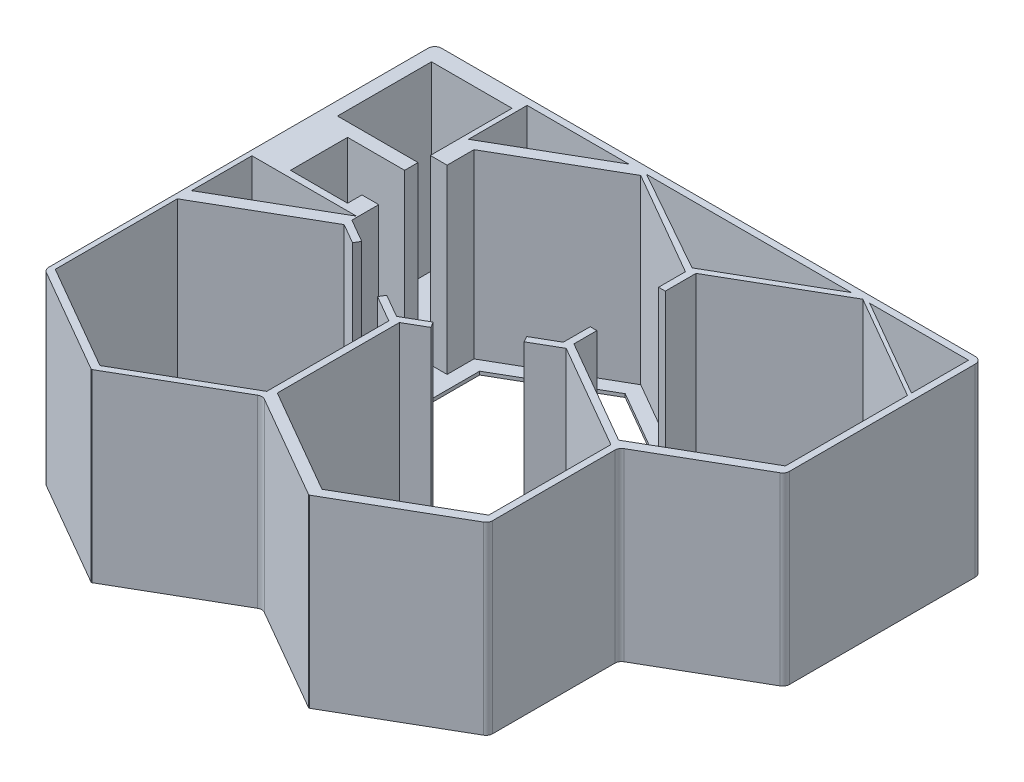
from build123d import *

# Parameters (mm, degrees)
SKETCH1_W               = 207.01
SKETCH1_H               = 171.45
BOSS_EXTRUDE1_DEPTH     = 69.85
CUT_EXTRUDE1_DEPTH      = 68.58
CUT_EXTRUDE2_DEPTH      = 1
CUT_EXTRUDE2_DEPTH_BACK = 70.85
FILLET3_R               = 2.54


with BuildPart() as part:
    # Sketch1 → Boss-Extrude1 (new body)
    with BuildSketch(Plane(origin=(0, 0, 0), x_dir=(1, 0, 0), z_dir=(0, 1, 0))):
        with Locations((103.505, -85.725)):
            Rectangle(SKETCH1_W, SKETCH1_H)
    extrude(amount=BOSS_EXTRUDE1_DEPTH)

    # Sketch3 → Cut-Extrude1 (cut)
    with BuildSketch(Plane(origin=(0, 69.85, 0), x_dir=(1, 0, 0), z_dir=(0, 1, 0))):
        Polygon((1.905, -93.98), (41.499681461, -71.12), (1.905, -71.12), align=None)
        Polygon((41.91, -76.230101608), (1.905, -99.326999127), (1.905, -145.520794165), (41.91, -168.617691684), (81.915, -145.520794165), (81.915, -99.326999127), (71.846181898, -93.513764285), (73.116181898, -91.314059759), (81.915, -96.394059759), (90.713818102, -91.314059759), (91.983818102, -93.513764285), (84.455, -97.860529443), (84.455, -144.054324481), (124.46, -167.151222), (164.465, -144.054324481), (164.465, -97.860529443), (124.46, -74.763631924), (114.391181898, -80.576866766), (113.121181898, -78.377162241), (121.92, -73.297162241), (121.92, -63.137162241), (124.46, -63.137162241), (124.46, -71.830692557), (164.465, -94.927590076), (204.47, -71.830692557), (204.47, -25.636897519), (164.465, -2.54), (124.46, -25.636897519), (124.46, -37.263367203), (121.92, -37.263367203), (121.92, -27.103367203), (81.915, -4.006469684), (41.91, -27.103367203), (41.91, -37.263367203), (35.56, -37.263367203), (35.56, -6.35), (5.08, -6.35), (5.08, -41.91), (35.56, -41.91), (35.56, -46.99), (13.97, -46.99), (13.97, -68.58), (35.56, -68.58), (35.56, -63.137162241), (41.91, -63.137162241), (41.91, -73.297162241), (50.708818102, -78.377162241), (49.438818102, -80.576866766), align=None)
        Polygon((37.465, -24.765), (75.959829198, -2.54), (37.465, -2.54), align=None)
        Polygon((167.075023065, -2.54), (204.47, -24.13), (204.47, -2.54), align=None)
        Polygon((82.645969059, -2.54), (121.92, -24.592453018), (160.115969059, -2.54), align=None)
    extrude(amount=-CUT_EXTRUDE1_DEPTH, mode=Mode.SUBTRACT)

    # Sketch4 → Cut-Extrude2 (cut, two sides)
    with BuildSketch(Plane(origin=(0, 69.85, 0), x_dir=(1, 0, 0), z_dir=(0, 1, 0))) as cut_extrude2_sk:
        Polygon((207.01, -74.315776706), (167.005, -97.412674225), (167.005, -146.601672765), (123.966434747, -171.45), (167.005, -171.45), (207.01, -171.45), align=None)
        Polygon((0, -147.53821025), (41.416434747, -171.45), (0, -171.45), align=None)
        Polygon((41.670434747, -171.45), (123.712434747, -171.45), (82.691434747, -147.766514608), align=None)
        Polygon((81.915, -9.872348419), (46.99, -30.03630657), (46.99, -70.364222873), (81.915, -90.528181024), (116.84, -70.364222873), (116.84, -30.03630657), align=None)
        Polygon((164.465, -8.405878735), (129.54, -28.569836886), (129.54, -68.897753189), (164.465, -89.061711341), (199.39, -68.897753189), (199.39, -28.569836886), align=None)
        Polygon((41.91, -82.095980343), (6.985, -102.259938494), (6.985, -142.587854797), (41.91, -162.751812949), (76.835, -142.587854797), (76.835, -102.259938494), align=None)
        Polygon((124.46, -80.629510659), (89.535, -100.793468811), (89.535, -141.121385114), (124.46, -161.285343265), (159.385, -141.121385114), (159.385, -100.793468811), align=None)
    extrude(amount=CUT_EXTRUDE2_DEPTH, mode=Mode.SUBTRACT)
    extrude(cut_extrude2_sk.sketch, amount=-CUT_EXTRUDE2_DEPTH_BACK, mode=Mode.SUBTRACT)

    # Fillet3
    fillet3_edges = [part.edges().sort_by_distance(p)[0] for p in [
        (0, 34.925, 147.53821025),
        (82.691434747, 34.925, 147.766514608),
        (207.01, 34.925, 74.315776706),
        (167.005, 34.925, 146.601672765),
        (167.005, 34.925, 97.412674225),
        (0, 34.925, 0),
        (207.01, 34.925, 0),
    ]]
    fillet(fillet3_edges, radius=FILLET3_R)


solid = part.part
